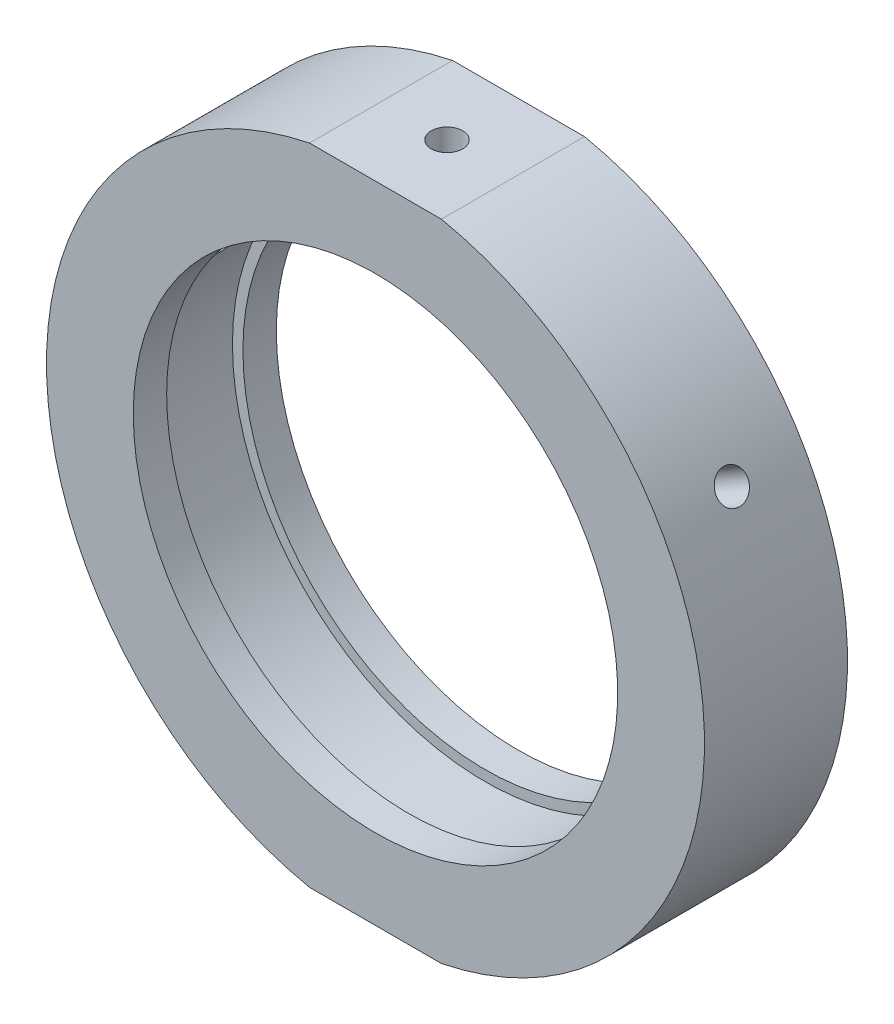
from build123d import *

# Parameters (mm, degrees)
SKETCH_2_W                       = 64.02174429
SKETCH_2_H                       = 9.248919907
CUT_EXTRUDE_1_DEPTH              = 49
HOLE_WIZARD_M4_2_D               = 3.3
HOLE_WIZARD_M4_2_DEPTH           = 5.5
HOLE_WIZARD_M4_2_TIP             = 0.991420021
HOLE_WIZARD_M6_2_D               = 5
HOLE_WIZARD_M6_2_DEPTH           = 5.5
HOLE_WIZARD_M6_2_TIP             = 1.502151548
HOLE_WIZARD_M4_3_D               = 3.3
HOLE_WIZARD_M4_3_DEPTH           = 13.4
HOLE_WIZARD_M4_3_TIP             = 0.991420021
HOLE_WIZARD_M4_3_ON_FACE_2_D     = 3.3
HOLE_WIZARD_M4_3_ON_FACE_2_DEPTH = 13.4
HOLE_WIZARD_M4_3_ON_FACE_2_TIP   = 0.991420021


with BuildPart() as part:
    # 草图1 → 旋转1 (revolve)
    with BuildSketch(Plane(origin=(0, 0, 0), x_dir=(1, 0, 0), z_dir=(0, 1, 0)), mode=Mode.PRIVATE) as revolve_1_sk:
        Polygon((34.5, 7.5), (34.5, -7.5), (25.4, -7.5), (25.4, -4), (26.5, -4), (26.5, 4), (25.4, 4), (25.4, 7.5), align=None)
    revolve(revolve_1_sk.sketch.rotate(Axis((0, 0, -31.9390681), (0, 0, 1)), 180), axis=Axis((0, 0, -31.9390681), (0, 0, 1)))  # turned: the seam where the file's is

    # 草图2 → 切除-拉伸1 (cut)
    with BuildSketch(Plane.XY.offset(7.5)):
        with Locations((-1.141100508, 38.424459954)):
            Rectangle(SKETCH_2_W, SKETCH_2_H)
        with Locations((-1.141100508, -38.424459954)):
            Rectangle(SKETCH_2_W, SKETCH_2_H)
    extrude(amount=-CUT_EXTRUDE_1_DEPTH, mode=Mode.SUBTRACT)

    # M4 螺纹孔2
    with Locations(Plane(origin=(0, 33.8, 0), x_dir=(1, 0, 0), z_dir=(0, 1, 0))):
        with Locations((0, 0)):
            Hole(HOLE_WIZARD_M4_2_D / 2, depth=HOLE_WIZARD_M4_2_DEPTH)
            with Locations((0, 0, -(HOLE_WIZARD_M4_2_DEPTH + HOLE_WIZARD_M4_2_TIP / 2))):  # 118° drill point
                Cone(0, HOLE_WIZARD_M4_2_D / 2, HOLE_WIZARD_M4_2_TIP, mode=Mode.SUBTRACT)

    # M6 螺纹孔2
    with Locations(Plane(origin=(0, -33.8, 0), x_dir=(-1, 0, 0), z_dir=(0, -1, 0))):
        with Locations((0, 0)):
            Hole(HOLE_WIZARD_M6_2_D / 2, depth=HOLE_WIZARD_M6_2_DEPTH)
            with Locations((0, 0, -(HOLE_WIZARD_M6_2_DEPTH + HOLE_WIZARD_M6_2_TIP / 2))):  # 118° drill point
                Cone(0, HOLE_WIZARD_M6_2_D / 2, HOLE_WIZARD_M6_2_TIP, mode=Mode.SUBTRACT)

    # M4 螺纹孔3
    with Locations(Plane(origin=(29.877876431, 17.25, 0), x_dir=(-0.5, 0.866025404, 0), z_dir=(0.866025404, 0.5, 0))):
        with Locations((0, 0)):
            Hole(HOLE_WIZARD_M4_3_D / 2, depth=HOLE_WIZARD_M4_3_DEPTH)
            with Locations((0, 0, -(HOLE_WIZARD_M4_3_DEPTH + HOLE_WIZARD_M4_3_TIP / 2))):  # 118° drill point
                Cone(0, HOLE_WIZARD_M4_3_D / 2, HOLE_WIZARD_M4_3_TIP, mode=Mode.SUBTRACT)

    # M4 螺纹孔3 on face 2
    with Locations(Plane(origin=(-29.877876431, 17.25, 0), x_dir=(-0.500000175, -0.866025303, 0), z_dir=(-0.866025303, 0.500000175, 0))):
        with Locations((0, 0)):
            Hole(HOLE_WIZARD_M4_3_ON_FACE_2_D / 2, depth=HOLE_WIZARD_M4_3_ON_FACE_2_DEPTH)
            with Locations((0, 0, -(HOLE_WIZARD_M4_3_ON_FACE_2_DEPTH + HOLE_WIZARD_M4_3_ON_FACE_2_TIP / 2))):  # 118° drill point
                Cone(0, HOLE_WIZARD_M4_3_ON_FACE_2_D / 2, HOLE_WIZARD_M4_3_ON_FACE_2_TIP, mode=Mode.SUBTRACT)


solid = part.part
